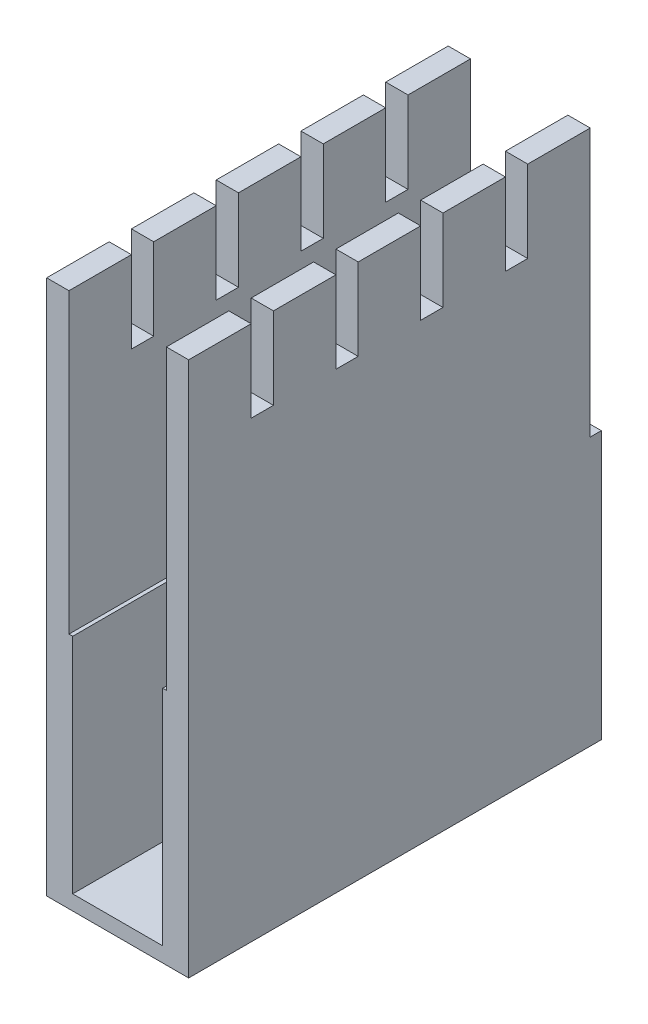
from build123d import *

# Parameters (mm, degrees)
BOSS_EXTRUDE1_DEPTH = 54
SKETCH2_W           = 3
SKETCH2_H           = 11
CUT_EXTRUDE1_DEPTH  = 20.1
SKETCH3_W           = 19.1
SKETCH3_H           = 36
BOSS_EXTRUDE2_DEPTH = 1.5


with BuildPart() as part:
    # Sketch1 → Boss-Extrude1 (new body)
    with BuildSketch(Plane.XY):
        Polygon((-9.55, 72), (-9.55, 0), (9.55, 0), (9.55, 72), (6.55, 72), (6.55, 32), (6.05, 32), (6.05, 2), (-6.05, 2), (-6.05, 32), (-6.55, 32), (-6.55, 72), align=None)
    extrude(amount=BOSS_EXTRUDE1_DEPTH)

    # Sketch2 → Cut-Extrude1 (cut, through all)
    with BuildSketch(Plane(origin=(9.55, 0, 0), x_dir=(0, 0, -1), z_dir=(1, 0, 0))):
        with Locations((-44.1, 66.5)):
            Rectangle(SKETCH2_W, SKETCH2_H)
        with Locations((-32.7, 66.5)):
            Rectangle(SKETCH2_W, SKETCH2_H)
        with Locations((-21.3, 66.5)):
            Rectangle(SKETCH2_W, SKETCH2_H)
        with Locations((-9.9, 66.5)):
            Rectangle(SKETCH2_W, SKETCH2_H)
    extrude(amount=-CUT_EXTRUDE1_DEPTH, mode=Mode.SUBTRACT)

    # Sketch3 → Boss-Extrude2 (add)
    with BuildSketch(Plane(origin=(0, 0, 0), x_dir=(-1, 0, 0), z_dir=(0, 0, -1))):
        with Locations((0, 18)):
            Rectangle(SKETCH3_W, SKETCH3_H)
    extrude(amount=BOSS_EXTRUDE2_DEPTH)


solid = part.part
